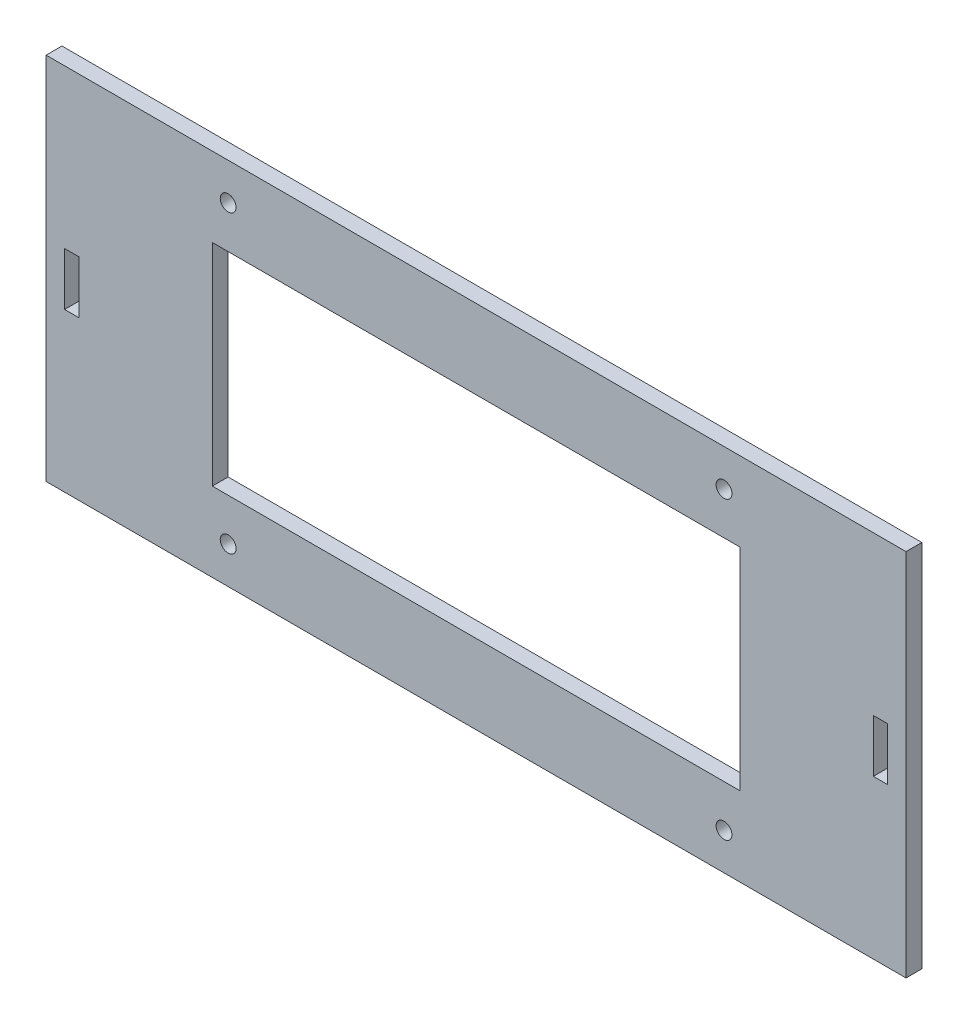
from build123d import *

# Parameters (mm, degrees)
SKETCH1_W               = 163
SKETCH1_H               = 70
BOSS_EXTRUDE1_DEPTH     = 3
SKETCH2_W               = 2.7
SKETCH2_H               = 10
CUT_EXTRUDE1_DEPTH      = 3
CUT_EXTRUDE2_REACH      = 5
SKETCH3_W               = 100
SKETCH3_H               = 40
SKETCH4_R               = 1.5
CUT_EXTRUDE3_DEPTH      = 3
MIRROR3_COPY_1_SKETCH_R = 1.5
MIRROR3_COPY_1_DEPTH    = 3


with BuildPart() as part:
    # Sketch1 → Boss-Extrude1 (new body)
    with BuildSketch(Plane.XY):
        Rectangle(SKETCH1_W, SKETCH1_H)
    extrude(amount=BOSS_EXTRUDE1_DEPTH)

    # Sketch2 → Cut-Extrude1 (cut)
    with BuildSketch(Plane.XY.offset(3)):
        with Locations((-76.65, 0)):
            Rectangle(SKETCH2_W, SKETCH2_H)
    cut_extrude1 = extrude(amount=-CUT_EXTRUDE1_DEPTH, mode=Mode.SUBTRACT)

    # Mirror1: Cut-Extrude1 across plane
    add(cut_extrude1.mirror(Plane(origin=(0, 0, 0), x_dir=(0, 0, 1), z_dir=(1, 0, 0))), mode=Mode.SUBTRACT)

    # Sketch3 → Cut-Extrude2 (cut, up to next)
    with BuildSketch(Plane.XY.offset(3), mode=Mode.PRIVATE) as cut_extrude2_sk1:
        Rectangle(SKETCH3_W, SKETCH3_H)
    cut_extrude2_tool1 = extrude(cut_extrude2_sk1.sketch, amount=-CUT_EXTRUDE2_REACH, mode=Mode.PRIVATE) & part.part
    add(cut_extrude2_tool1.solids().sort_by_distance((0, 0, 3))[0], mode=Mode.SUBTRACT)

    # Sketch4 → Cut-Extrude3 (cut)
    with BuildSketch(Plane.XY.offset(3)):
        with Locations((47, 28)):
            Circle(SKETCH4_R)
    cut_extrude3 = extrude(amount=-CUT_EXTRUDE3_DEPTH, mode=Mode.SUBTRACT)

    # Mirror2: Cut-Extrude3 across plane
    add(cut_extrude3.mirror(Plane(origin=(0, 0, 0), x_dir=(0, 0, 1), z_dir=(1, 0, 0))), mode=Mode.SUBTRACT)

    # Mirror3: Cut-Extrude3 across plane
    add(cut_extrude3.mirror(Plane.ZX), mode=Mode.SUBTRACT)

    # Mirror3 copy 1 sketch → Mirror3 copy 1 (cut)
    with BuildSketch(Plane(origin=(0, 0, 3), x_dir=(-1, 0, 0), z_dir=(0, 0, 1))):
        with Locations((47, 28)):
            Circle(MIRROR3_COPY_1_SKETCH_R)
    extrude(amount=-MIRROR3_COPY_1_DEPTH, mode=Mode.SUBTRACT)


solid = part.part
